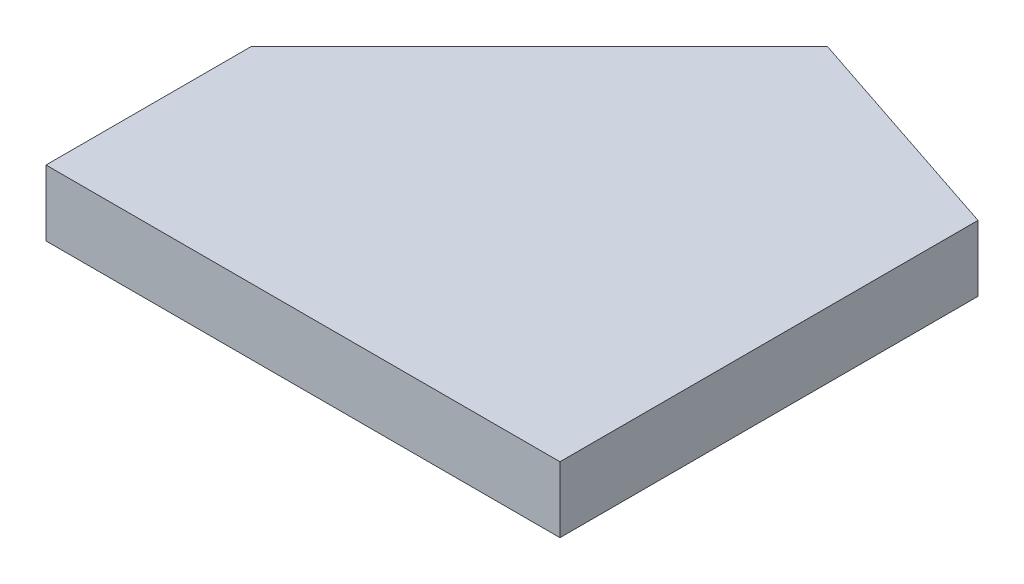
from build123d import *

# Parameters (mm, degrees)
EXTRUDE_B_DEPTH = 6.4


with BuildPart() as part:
    # puzzle plan_3 → Extrude B (new body)
    with BuildSketch(Plane(origin=(0, 0, 0), x_dir=(1, 0, 0), z_dir=(0, 1, 0))):
        Polygon((28, 48), (0, 20), (0, 0), (50, 0), (50, 40.666666667), align=None)
    extrude(amount=EXTRUDE_B_DEPTH)


solid = part.part
